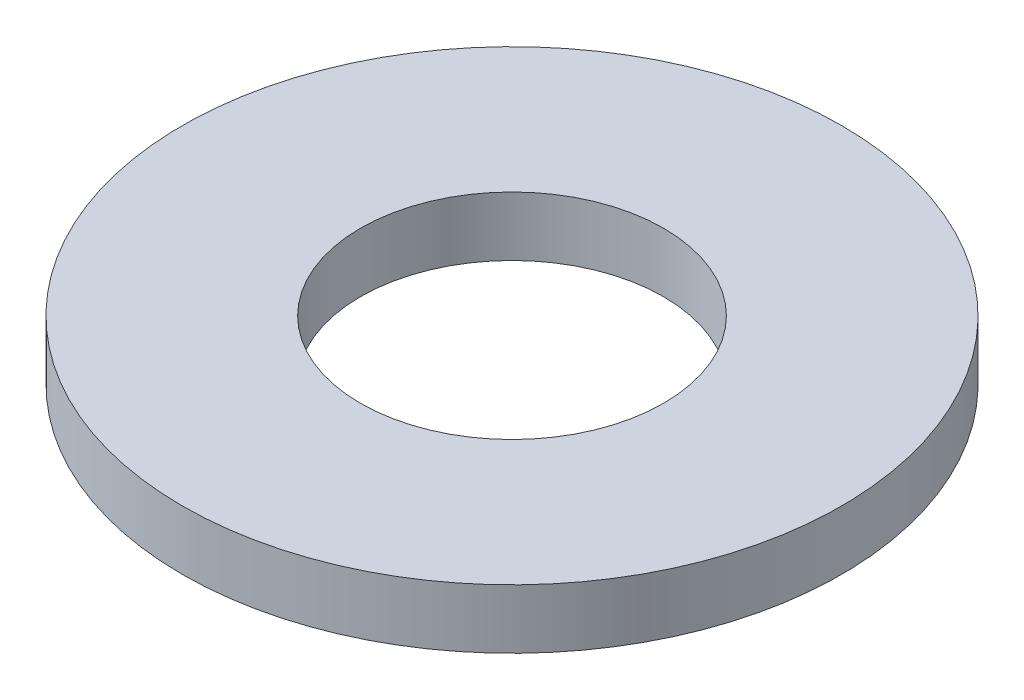
from build123d import *

# Parameters (mm, degrees)
SKETCH1_R           = 12.5
SKETCH1_R_2         = 5.75
BOSS_EXTRUDE1_DEPTH = 1.125


with BuildPart() as part:
    # Sketch1 → Boss-Extrude1 (new body, symmetric)
    with BuildSketch(Plane(origin=(0, 0, 0), x_dir=(1, 0, 0), z_dir=(0, 1, 0))):
        Circle(SKETCH1_R)
        Circle(SKETCH1_R_2, mode=Mode.SUBTRACT)
    extrude(amount=BOSS_EXTRUDE1_DEPTH, both=True)


solid = part.part
